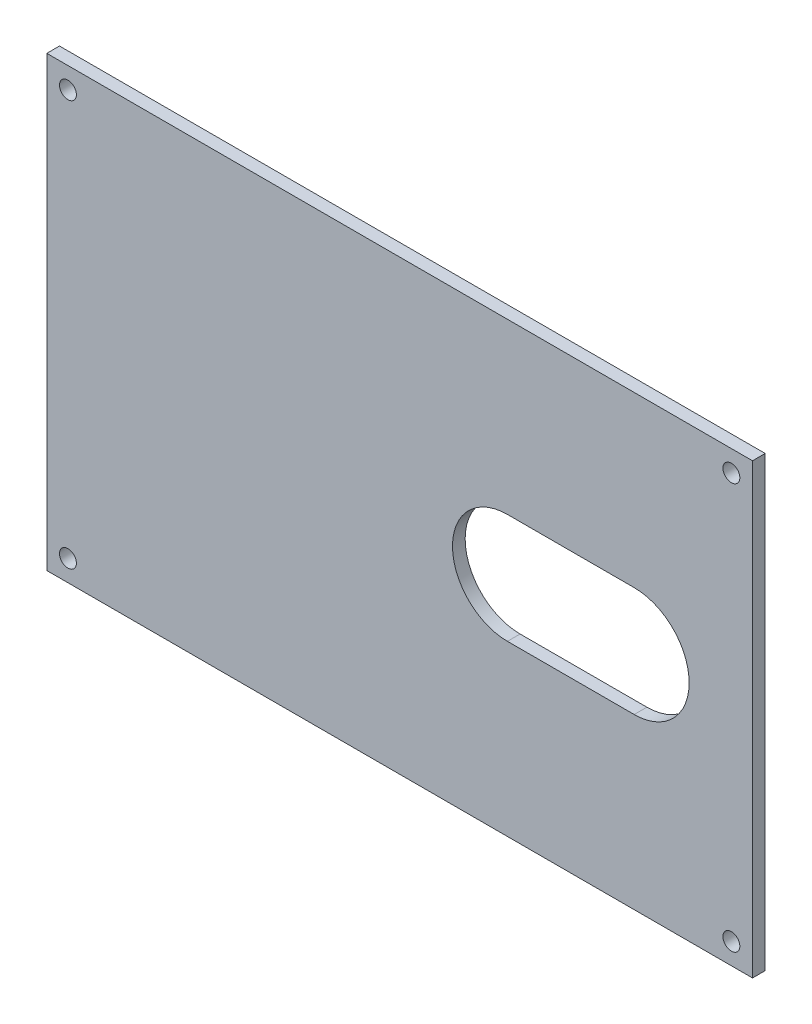
from build123d import *

# Parameters (mm, degrees)
SKETCH1_W           = 167
SKETCH1_H           = 106
SKETCH1_R           = 2
BOSS_EXTRUDE1_DEPTH = 3


with BuildPart() as part:
    # Sketch1 → Boss-Extrude1 (new body)
    with BuildSketch(Plane(origin=(0, 0, 0), x_dir=(-1, 0, 0), z_dir=(0, 0, 1))):
        with Locations((-80.5, 50)):
            Rectangle(SKETCH1_W, SKETCH1_H)
        with Locations((-159, 98)):
            Circle(SKETCH1_R, mode=Mode.SUBTRACT)
        with Locations((-2, 98)):
            Circle(SKETCH1_R, mode=Mode.SUBTRACT)
        with Locations((-2, 2)):
            Circle(SKETCH1_R, mode=Mode.SUBTRACT)
        with Locations((-159, 2)):
            Circle(SKETCH1_R, mode=Mode.SUBTRACT)
        with BuildLine():
            Line((-136, 63), (-106, 63))
            ThreePointArc((-106, 63), (-93, 50), (-106, 37))
            Line((-106, 37), (-136, 37))
            ThreePointArc((-136, 37), (-149, 50), (-136, 63))
        make_face(mode=Mode.SUBTRACT)
    extrude(amount=BOSS_EXTRUDE1_DEPTH)


solid = part.part
